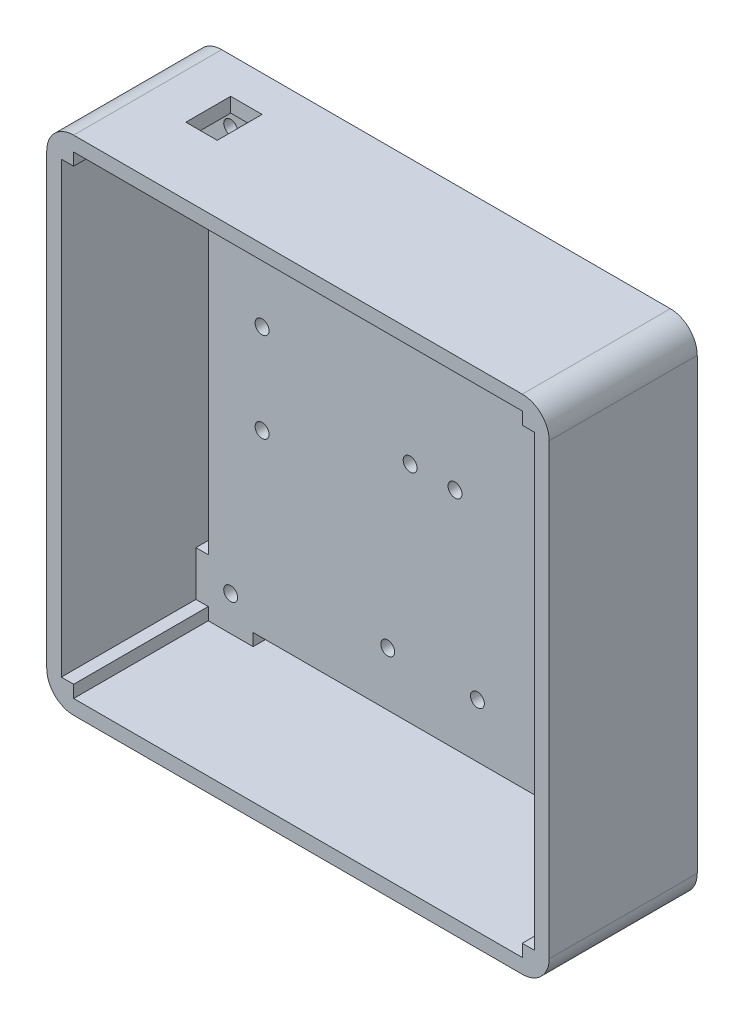
from build123d import *

# Parameters (mm, degrees)
SKETCH_1_R          = 1.55
EXTRUDE_4_DEPTH     = 3
EXTRUDE_5_DEPTH     = 33
SKETCH_3_W          = 7
SKETCH_3_H          = 10
CUT_EXTRUDE_1_DEPTH = 6


with BuildPart() as part:
    # 草图1 → 凸台-拉伸4 (new body)
    with BuildSketch(Plane.XY):
        Polygon((0, 10), (-2.75, 10), (-2.75, 0), (0, 0), (0, -2.75), (10, -2.75), (10, 0), (50, 0), (90, 0), (90, -2.75), (100, -2.75), (100, 0), (102.75, 0), (102.75, 10), (100, 10), (100, 90), (102.75, 90), (102.75, 100), (100, 100), (100, 102.75), (90, 102.75), (90, 100), (50, 100), (10, 100), (10, 102.75), (0, 102.75), (0, 100), (-2.75, 100), (-2.75, 90), (0, 90), align=None)
        with Locations((45, 50)):
            Circle(SKETCH_1_R, mode=Mode.SUBTRACT)
        with Locations((55, 50)):
            Circle(SKETCH_1_R, mode=Mode.SUBTRACT)
        with Locations((5, 5)):
            Circle(SKETCH_1_R, mode=Mode.SUBTRACT)
        with Locations((95, 5)):
            Circle(SKETCH_1_R, mode=Mode.SUBTRACT)
        with Locations((40, 12)):
            Circle(SKETCH_1_R, mode=Mode.SUBTRACT)
        with Locations((60, 12)):
            Circle(SKETCH_1_R, mode=Mode.SUBTRACT)
        with Locations((95, 95)):
            Circle(SKETCH_1_R, mode=Mode.SUBTRACT)
        with Locations((5, 95)):
            Circle(SKETCH_1_R, mode=Mode.SUBTRACT)
        with Locations((12, 40)):
            Circle(SKETCH_1_R, mode=Mode.SUBTRACT)
        with Locations((88, 40)):
            Circle(SKETCH_1_R, mode=Mode.SUBTRACT)
        with Locations((88, 60)):
            Circle(SKETCH_1_R, mode=Mode.SUBTRACT)
        with Locations((12, 60)):
            Circle(SKETCH_1_R, mode=Mode.SUBTRACT)
        with Locations((40, 88)):
            Circle(SKETCH_1_R, mode=Mode.SUBTRACT)
        with Locations((60, 88)):
            Circle(SKETCH_1_R, mode=Mode.SUBTRACT)
    extrude(amount=EXTRUDE_4_DEPTH)

    # 草图1<8> → 凸台-拉伸5 (add)
    with BuildSketch(Plane.XY):
        with BuildLine():
            ThreePointArc((-6, 0), (-4.242640687, -4.242640687), (0, -6))
            Line((0, -6), (100, -6))
            ThreePointArc((100, -6), (104.242640687, -4.242640687), (106, 0))
            Line((106, 0), (106, 100))
            ThreePointArc((106, 100), (104.242640687, 104.242640687), (100, 106))
            Line((100, 106), (0, 106))
            ThreePointArc((0, 106), (-4.242640687, 104.242640687), (-6, 100))
            Line((-6, 100), (-6, 0))
        make_face()
        Polygon((0, -2.75), (0, 0), (-2.75, 0), (-2.75, 100), (0, 100), (0, 102.75), (100, 102.75), (100, 100), (102.75, 100), (102.75, 0), (100, 0), (100, -2.75), align=None, mode=Mode.SUBTRACT)
    extrude(amount=EXTRUDE_5_DEPTH)

    # 草图3 → 切除-拉伸1 (cut)
    with BuildSketch(Plane.XZ.offset(-102.75)):
        with Locations((13.5, 13)):
            Rectangle(SKETCH_3_W, SKETCH_3_H)
    extrude(amount=-CUT_EXTRUDE_1_DEPTH, mode=Mode.SUBTRACT)


solid = part.part
